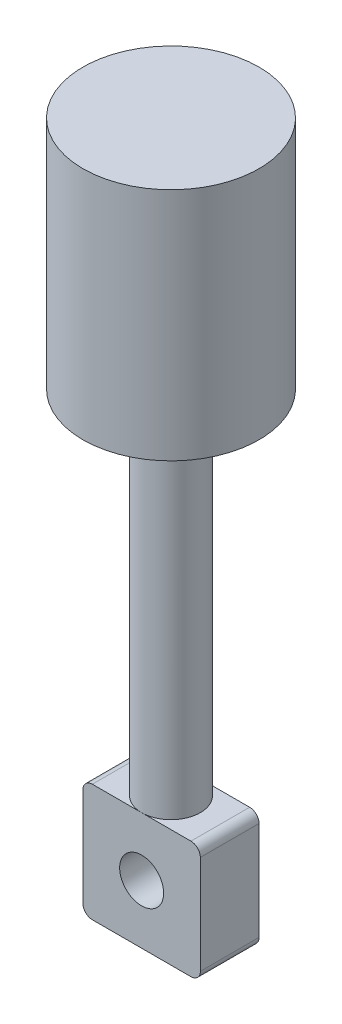
from build123d import *

# Parameters (mm, degrees)
SKETCH2_R           = 1.190625
BOSS_EXTRUDE2_DEPTH = 1.5875
SKETCH6_R           = 1.5875
BOSS_EXTRUDE5_DEPTH = 19.05
SKETCH7_R           = 4.7625
BOSS_EXTRUDE6_DEPTH = 12.7


with BuildPart() as part:
    # Sketch2 → Boss-Extrude2 (new body, symmetric)
    with BuildSketch(Plane.XY):
        with BuildLine():
            Line((-2.667, 3.175), (-1.5875, 3.175))
            Line((-1.5875, 3.175), (1.5875, 3.175))
            Line((1.5875, 3.175), (2.667, 3.175))
            ThreePointArc((2.667, 3.175), (3.026210245, 3.026210245), (3.175, 2.667))
            Line((3.175, 2.667), (3.175, -2.667))
            ThreePointArc((3.175, -2.667), (3.026210245, -3.026210245), (2.667, -3.175))
            Line((2.667, -3.175), (-2.667, -3.175))
            ThreePointArc((-2.667, -3.175), (-3.026210245, -3.026210245), (-3.175, -2.667))
            Line((-3.175, -2.667), (-3.175, 2.667))
            ThreePointArc((-3.175, 2.667), (-3.026210245, 3.026210245), (-2.667, 3.175))
        make_face()
        Circle(SKETCH2_R, mode=Mode.SUBTRACT)
    extrude(amount=BOSS_EXTRUDE2_DEPTH, both=True)

    # Sketch6 → Boss-Extrude5 (add)
    with BuildSketch(Plane(origin=(0, 3.175, 0), x_dir=(1, 0, 0), z_dir=(0, 1, 0))):
        Circle(SKETCH6_R)
    extrude(amount=BOSS_EXTRUDE5_DEPTH)

    # Sketch7 → Boss-Extrude6 (add)
    with BuildSketch(Plane(origin=(0, 22.225, 0), x_dir=(1, 0, 0), z_dir=(0, 1, 0))):
        Circle(SKETCH7_R)
    extrude(amount=BOSS_EXTRUDE6_DEPTH)


solid = part.part
